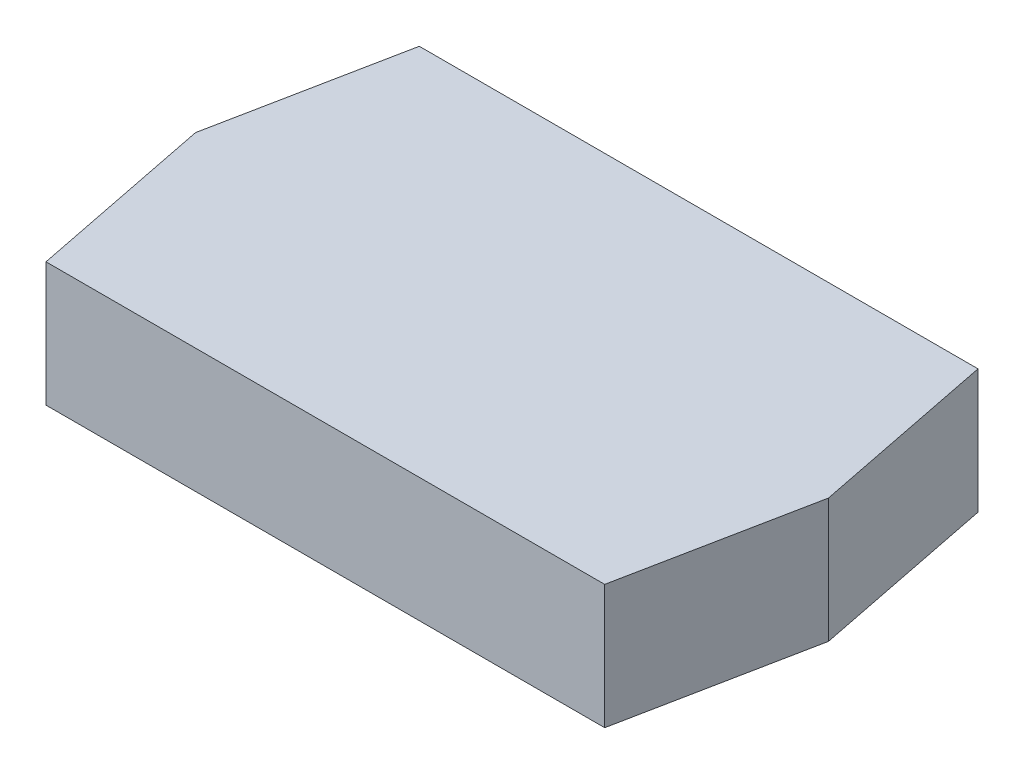
from build123d import *

# Parameters (mm, degrees)
BOSS_EXTRUDE1_DEPTH = 10


with BuildPart() as part:
    # Sketch1 → Boss-Extrude1 (new body)
    with BuildSketch(Plane(origin=(0, 0, 0), x_dir=(1, 0, 0), z_dir=(0, 1, 0))):
        Polygon((22.499405578, 15.033622173), (25.489778955, 0), (22.499405578, -15.033622173), (-22.499405578, -15.033622173), (-25.489778955, 0), (-22.499405578, 15.033622173), align=None)
    extrude(amount=BOSS_EXTRUDE1_DEPTH)


solid = part.part
